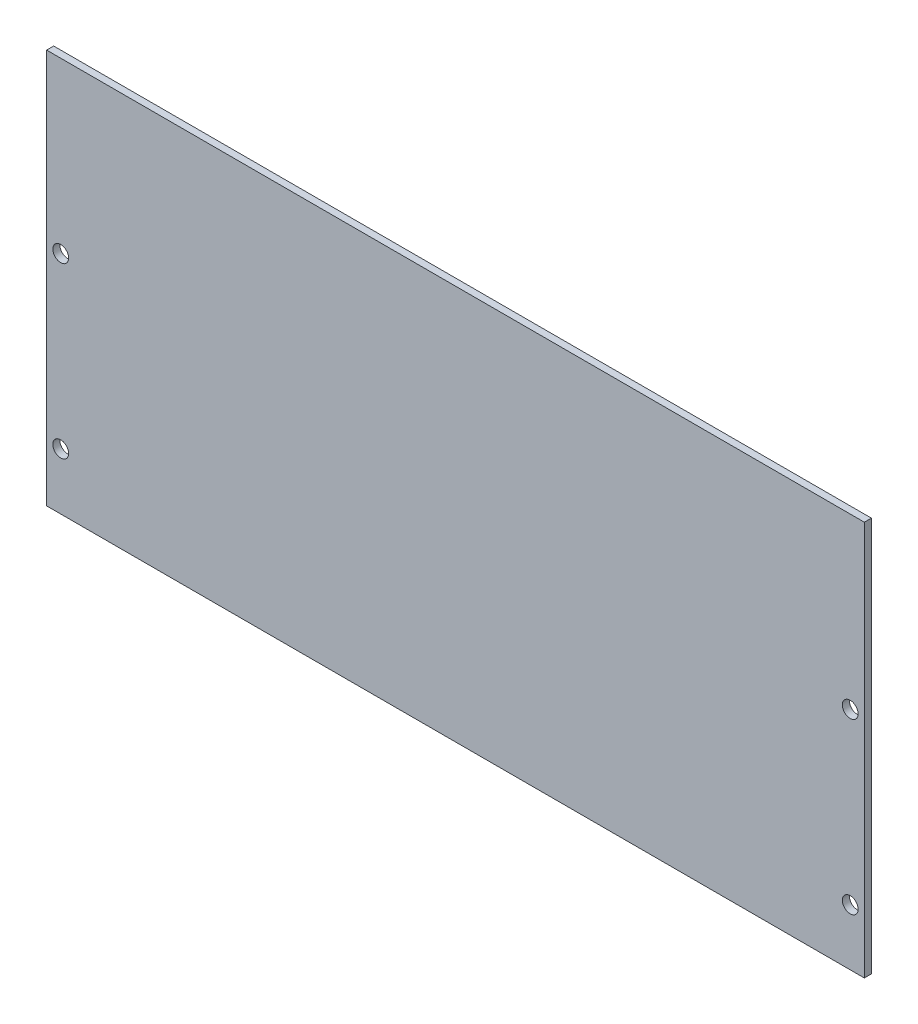
from build123d import *

# Parameters (mm, degrees)
SKETCH1_W           = 368.3
SKETCH1_H           = 177.8
SKETCH1_R           = 3.556
BOSS_EXTRUDE1_DEPTH = 3.175


with BuildPart() as part:
    # Sketch1 → Boss-Extrude1 (new body)
    with BuildSketch(Plane.XY):
        with Locations((0, 88.9)):
            Rectangle(SKETCH1_W, SKETCH1_H)
        with Locations((-177.8, 25.4)):
            Circle(SKETCH1_R, mode=Mode.SUBTRACT)
        with Locations((-177.8, 101.6)):
            Circle(SKETCH1_R, mode=Mode.SUBTRACT)
        with Locations((177.8, 101.6)):
            Circle(SKETCH1_R, mode=Mode.SUBTRACT)
        with Locations((177.8, 25.4)):
            Circle(SKETCH1_R, mode=Mode.SUBTRACT)
    extrude(amount=BOSS_EXTRUDE1_DEPTH)


solid = part.part
